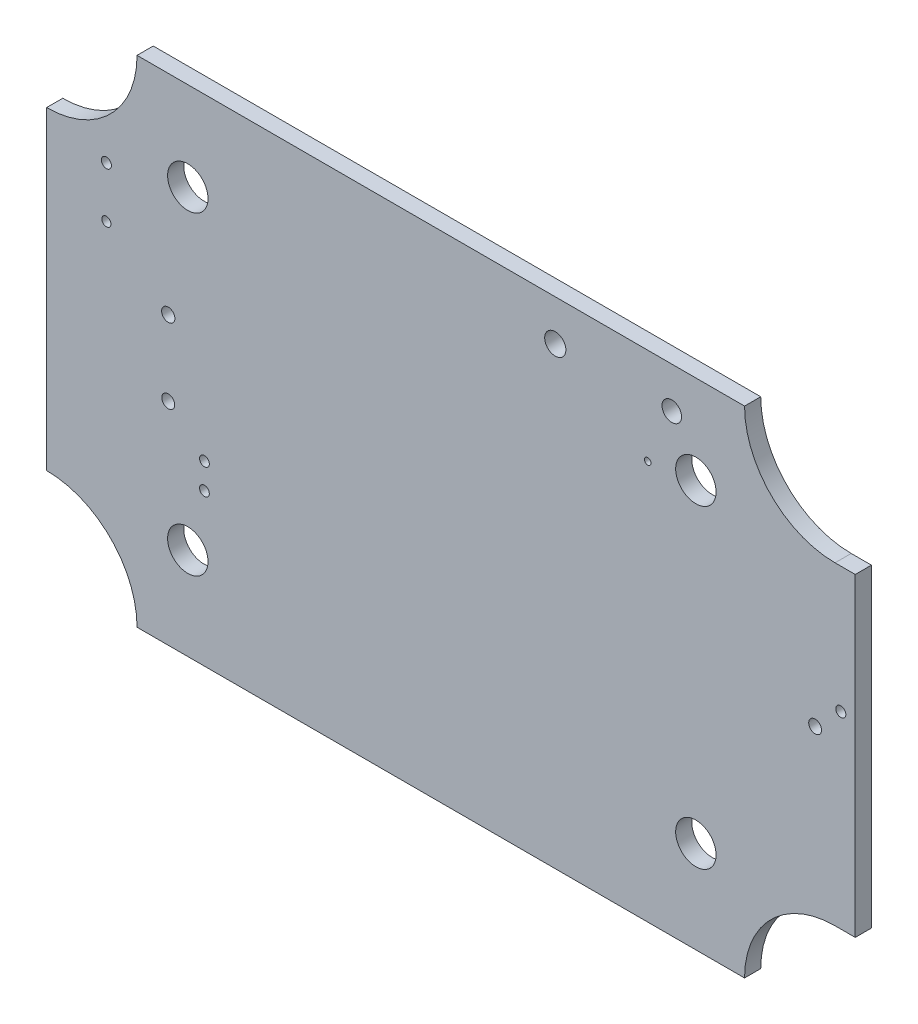
from build123d import *

# Parameters (mm, degrees)
SKETCH1_W           = 78
SKETCH1_H           = 49
BOSS_EXTRUDE1_DEPTH = 1.6
SKETCH2_R           = 8.951195902
CUT_EXTRUDE1_DEPTH  = 10
SKETCH4_W           = 1.6
SKETCH4_H           = 31.097608196
BOSS_EXTRUDE3_DEPTH = 2
SKETCH5_R           = 0.968115871
SKETCH5_R_2         = 1.048792193
SKETCH5_R_3         = 0.324209478
SKETCH5_R_4         = 0.640689511
SKETCH5_R_5         = 0.655195162
SKETCH5_R_6         = 0.453768234
SKETCH5_R_7         = 0.5
SKETCH5_R_8         = 0.4826
SKETCH5_R_9         = 0.635
CUT_EXTRUDE2_DEPTH  = 10
SKETCH6_R           = 2
CUT_EXTRUDE3_DEPTH  = 10


with BuildPart() as part:
    # Sketch1 → Boss-Extrude1 (new body)
    with BuildSketch(Plane.XY):
        Rectangle(SKETCH1_W, SKETCH1_H)
    extrude(amount=BOSS_EXTRUDE1_DEPTH)

    # Sketch2 → Cut-Extrude1 (cut)
    with BuildSketch(Plane.XY.offset(1.6)):
        with Locations((39, 24.5)):
            Circle(SKETCH2_R)
        with Locations((39, -24.5)):
            Circle(SKETCH2_R)
        with Locations((-39, 24.5)):
            Circle(SKETCH2_R)
        with Locations((-39, -24.5)):
            Circle(SKETCH2_R)
    extrude(amount=-CUT_EXTRUDE1_DEPTH, mode=Mode.SUBTRACT)

    # Sketch4 → Boss-Extrude3 (add)
    with BuildSketch(Plane(origin=(39, 0, 0), x_dir=(0, 0, -1), z_dir=(1, 0, 0))):
        with Locations((-0.8, 0)):
            Rectangle(SKETCH4_W, SKETCH4_H)
    extrude(amount=BOSS_EXTRUDE3_DEPTH)

    # Sketch5 → Cut-Extrude2 (cut)
    with BuildSketch(Plane(origin=(0, 0, 0), x_dir=(-1, 0, 0), z_dir=(0, 0, -1))):
        with Locations((-22.850936129, 20.463344351)):
            Circle(SKETCH5_R)
        with Locations((-11.32352045, 20.463344351)):
            Circle(SKETCH5_R_2)
        with Locations((-20.469685942, 14.979253011)):
            Circle(SKETCH5_R_3)
        with Locations((26.963692039, -3.596337313)):
            Circle(SKETCH5_R_4)
        with Locations((26.963692039, 3.820462687)):
            Circle(SKETCH5_R_5)
        with Locations((33.083891647, 8.744582154)):
            Circle(SKETCH5_R_6)
        with Locations((33.083891647, 13.778350388)):
            Circle(SKETCH5_R_7)
        with Locations((23.383432149, -9.480592582)):
            Circle(SKETCH5_R_8)
        with Locations((23.383432149, -6.940592582)):
            Circle(SKETCH5_R_8)
        with Locations((-39.570851538, 3.081777689)):
            Circle(SKETCH5_R_7)
        with Locations((-37.030851538, 0.541777689)):
            Circle(SKETCH5_R_9)
    extrude(amount=-CUT_EXTRUDE2_DEPTH, mode=Mode.SUBTRACT)

    # Sketch6 → Cut-Extrude3 (cut)
    with BuildSketch(Plane.XY.offset(1.6)):
        with Locations((25.232939878, -15.376639124)):
            Circle(SKETCH6_R)
        with Locations((-25.028046678, -15.376639124)):
            Circle(SKETCH6_R)
        with Locations((-25.028046678, 15.720969071)):
            Circle(SKETCH6_R)
        with Locations((25.232939878, 15.720969071)):
            Circle(SKETCH6_R)
    extrude(amount=-CUT_EXTRUDE3_DEPTH, mode=Mode.SUBTRACT)


solid = part.part
